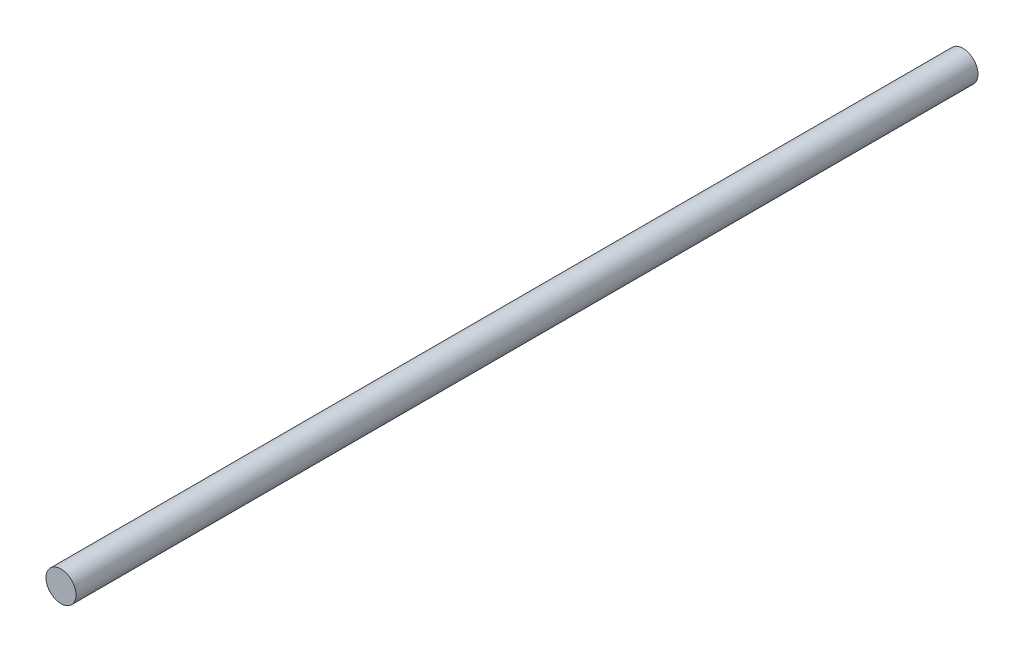
from build123d import *

# Parameters (mm, degrees)
CROQUIS1_R              = 5
SALIENTE_EXTRUIR1_DEPTH = 300


with BuildPart() as part:
    # Croquis1 → Saliente-Extruir1 (new body)
    with BuildSketch(Plane.XY):
        Circle(CROQUIS1_R)
    extrude(amount=SALIENTE_EXTRUIR1_DEPTH)


solid = part.part
